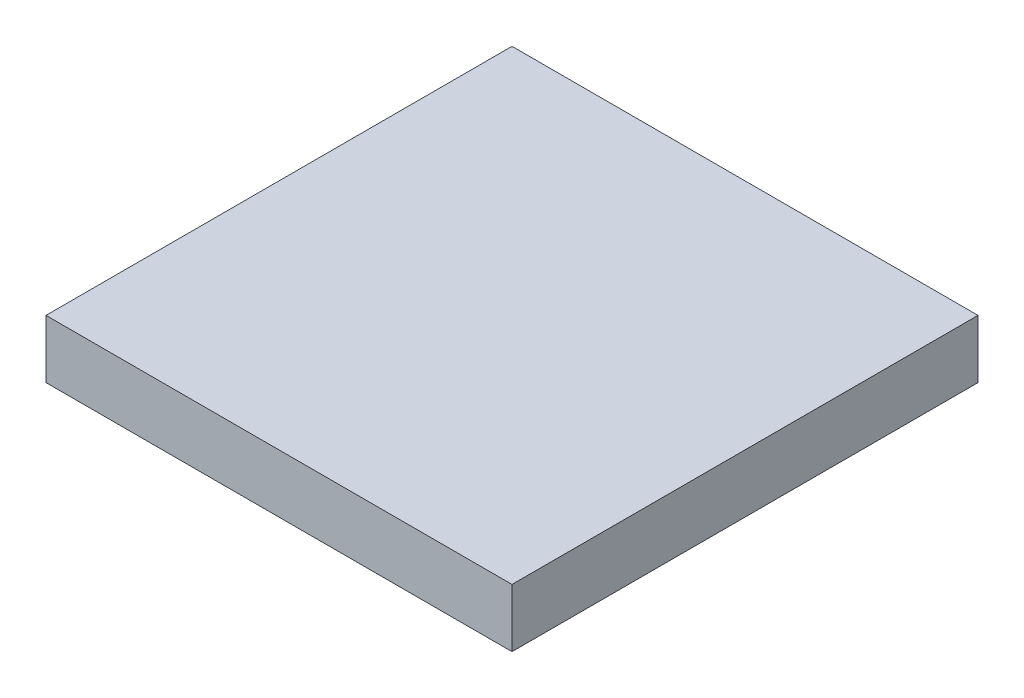
from build123d import *

# Parameters (mm, degrees)
SKETCH1_W           = 25.4
SKETCH1_H           = 25.4
BOSS_EXTRUDE1_DEPTH = 3.175


with BuildPart() as part:
    # Sketch1 → Boss-Extrude1 (new body)
    with BuildSketch(Plane(origin=(0, 0, 0), x_dir=(1, 0, 0), z_dir=(0, 1, 0))):
        Rectangle(SKETCH1_W, SKETCH1_H)
    extrude(amount=BOSS_EXTRUDE1_DEPTH)


solid = part.part
